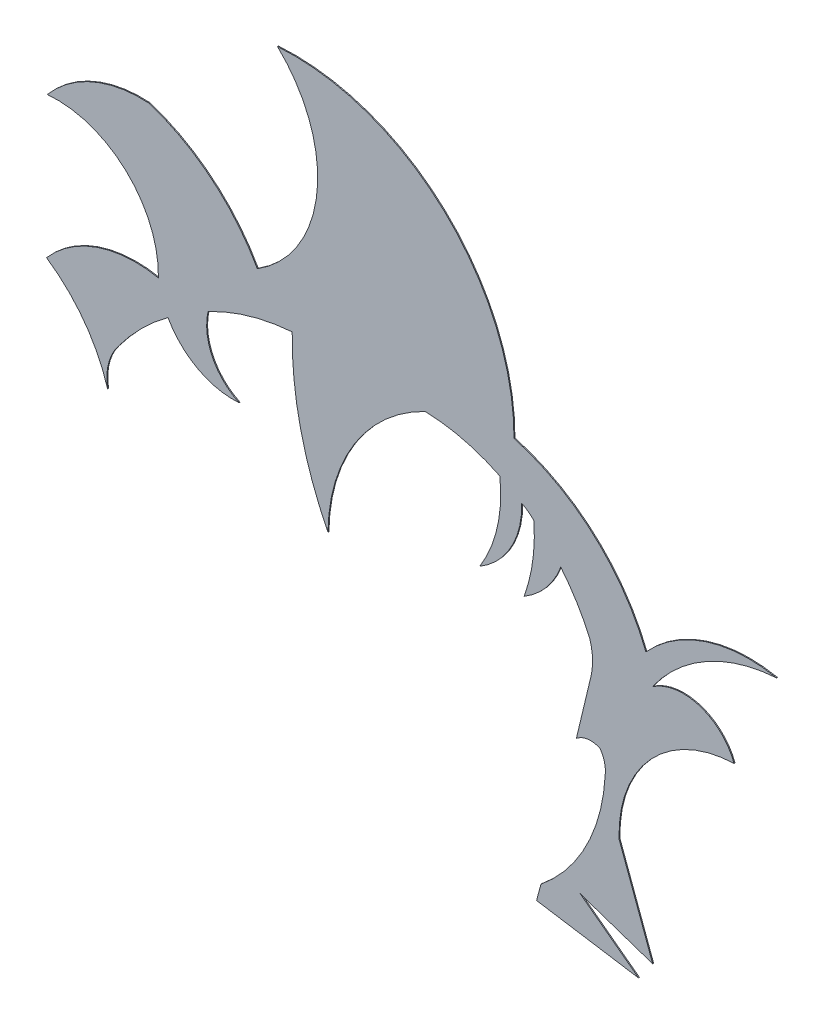
from build123d import *

# Parameters (mm, degrees)
SALIENTE_EXTRUIR1_DEPTH = 0.1


with BuildPart() as part:
    # Model → Saliente-Extruir1 (new body)
    with BuildSketch(Plane.XY):
        with BuildLine():
            Line((46.781292642, 16.163412143), (45.210633071, 9.597207197))
            ThreePointArc((45.210633071, 9.597207197), (46.428733439, 10.136393874), (47.745640238, 9.935776663))
            ThreePointArc((47.745640238, 9.935776663), (48.227185328, 8.874486831), (48.29361035, 7.710953635))
            ThreePointArc((48.29361035, 7.710953635), (46.29339053, 0.212855495), (41.414561099, -5.821991516))
            Line((41.414561099, -5.821991516), (40.94311821, -7.574533899))
            Line((40.94311821, -7.574533899), (51.874825524, -9.299930098))
            Line((51.874825524, -9.299930098), (45.610263372, -4.601508484))
            Line((45.610263372, -4.601508484), (53.387805188, -7.231700789))
            Line((53.387805188, -7.231700789), (49.78663814, 2.533131744))
            ThreePointArc((49.78663814, 2.533131744), (53.21025646, 11.68516332), (62.108805747, 15.722076119))
            ThreePointArc((62.108805747, 15.722076119), (58.405273393, 19.222364472), (53.363625788, 18.480771672))
            ThreePointArc((53.363625788, 18.480771672), (59.163542766, 23.716796233), (66.656485293, 25.932829273))
            ThreePointArc((66.656485293, 25.932829273), (59.050669494, 25.500073296), (52.661184456, 21.351556375))
            ThreePointArc((52.661184456, 21.351556375), (47.085279202, 29.377399858), (38.526658627, 34.094909461))
            ThreePointArc((38.526658627, 34.094909461), (31.0230825, 51.465775367), (13.185822242, 57.781057111))
            ThreePointArc((13.185822242, 57.781057111), (17.428790822, 46.402823396), (11.027622368, 36.083325964))
            ThreePointArc((11.027622368, 36.083325964), (6.141614269, 41.955490113), (-0.549240207, 45.641660661))
            ThreePointArc((-0.549240207, 45.641660661), (-6.565835805, 44.626508675), (-11.474115224, 41.001767403))
            ThreePointArc((-11.474115224, 41.001767403), (-3.043112078, 38.133520464), (0.430717912, 29.933449747))
            ThreePointArc((0.430717912, 29.933449747), (-6.1199859, 29.496958972), (-11.558821293, 25.819825005))
            ThreePointArc((-11.558821293, 25.819825005), (-7.516746047, 21.932992962), (-5.013290934, 16.915169916))
            ThreePointArc((-5.013290934, 16.915169916), (-4.924563846, 19.307742761), (-3.862473188, 21.453492221))
            ThreePointArc((-3.862473188, 21.453492221), (-1.404763761, 24.311648506), (1.453102003, 26.769695749))
            ThreePointArc((1.453102003, 26.769695749), (4.666243247, 23.605511541), (9.078509713, 22.673715965))
            ThreePointArc((9.078509713, 22.673715965), (6.210508457, 25.484631427), (5.747363145, 29.473637989))
            ThreePointArc((5.747363145, 29.473637989), (10.121021769, 31.249866453), (14.765165078, 32.095922149))
            ThreePointArc((14.765165078, 32.095922149), (15.665979392, 23.525430747), (18.59573809, 15.421030506))
            ThreePointArc((18.59573809, 15.421030506), (21.47392467, 25.106483656), (29.012326443, 31.834370355))
            ThreePointArc((29.012326443, 31.834370355), (33.11905298, 31.270823266), (37.01078738, 29.843521077))
            ThreePointArc((37.01078738, 29.843521077), (36.737947796, 24.937066035), (34.858893184, 20.396482781))
            ThreePointArc((34.858893184, 20.396482781), (38.209567477, 23.825829531), (39.356591195, 28.481124787))
            ThreePointArc((39.356591195, 28.481124787), (40.05251455, 28.065666009), (40.657061832, 27.525816125))
            ThreePointArc((40.657061832, 27.525816125), (40.534478216, 23.70157311), (39.613613517, 19.987832464))
            ThreePointArc((39.613613517, 19.987832464), (41.978685113, 21.980935805), (43.538467404, 24.651722914))
            ThreePointArc((43.538467404, 24.651722914), (45.261167282, 22.234594253), (46.637218774, 19.604634534))
            ThreePointArc((46.637218774, 19.604634534), (46.937945055, 17.893597889), (46.781292642, 16.163412143))
        make_face()
    extrude(amount=SALIENTE_EXTRUIR1_DEPTH)


solid = part.part
